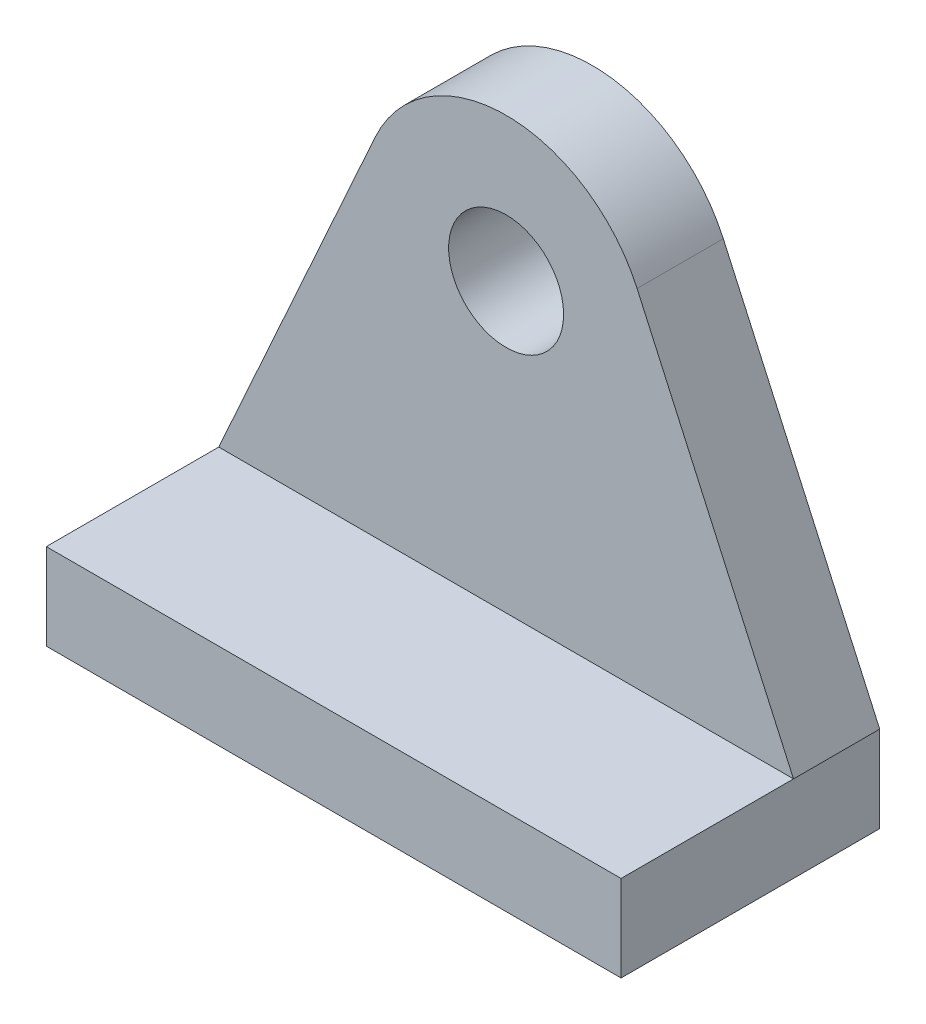
from build123d import *

# Parameters (mm, degrees)
SKETCH_1_R      = 2
EXTRUDE_1_DEPTH = 3
SKETCH_2_W      = 20
SKETCH_2_H      = 3
EXTRUDE_2_DEPTH = 9


with BuildPart() as part:
    # 草图1 → 凸台-拉伸1 (new body)
    with BuildSketch(Plane.XY):
        with BuildLine():
            Line((0, -10), (-10, -10))
            Line((-10, -10), (-4.557189139, 2.057189139))
            ThreePointArc((-4.557189139, 2.057189139), (0, 5), (4.557189139, 2.057189139))
            Line((4.557189139, 2.057189139), (10, -10))
            Line((10, -10), (0, -10))
        make_face()
        Circle(SKETCH_1_R, mode=Mode.SUBTRACT)
    extrude(amount=EXTRUDE_1_DEPTH)

    # 草图2 → 凸台-拉伸2 (add)
    with BuildSketch(Plane(origin=(0, 0, 0), x_dir=(-1, 0, 0), z_dir=(0, 0, -1))):
        with Locations((0, -11.5)):
            Rectangle(SKETCH_2_W, SKETCH_2_H)
    extrude(amount=-EXTRUDE_2_DEPTH)


solid = part.part
